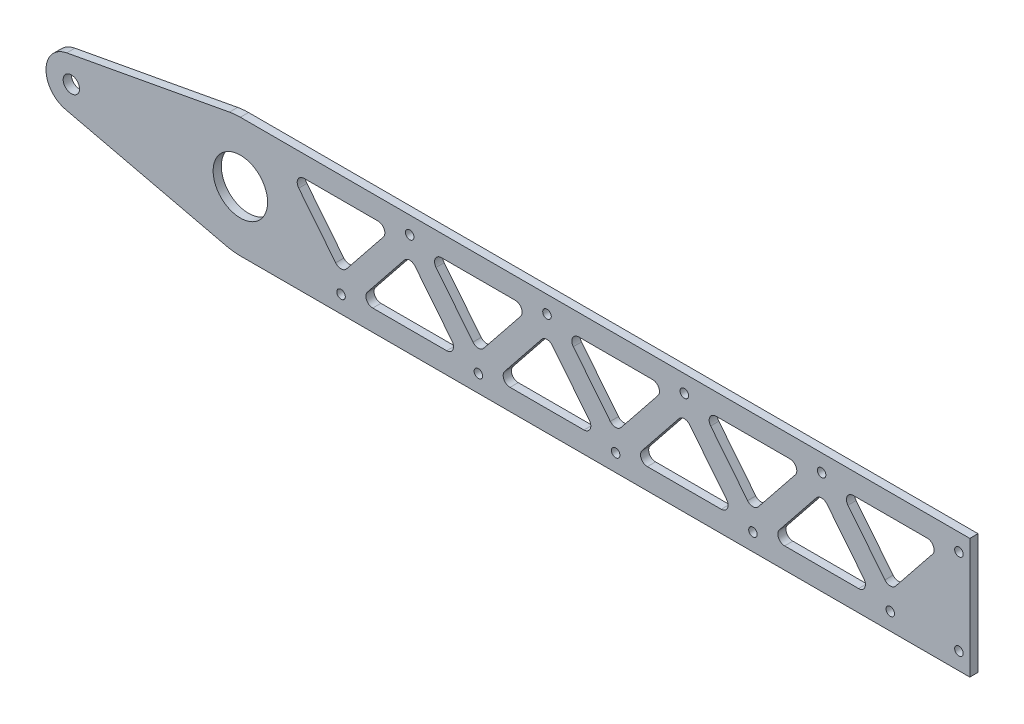
from build123d import *

# Parameters (mm, degrees)
SKETCH1_R                  = 15.875
SKETCH1_R_2                = 4.7625
BOSS_EXTRUDE1_DEPTH        = 4.7625
F_10_CLEARANCE_HOLE1_D     = 4.9784
LPATTERN1_COUNT            = 4
LPATTERN1_PITCH            = 80
CUT_EXTRUDE1_DEPTH         = 10
FILLET1_R                  = 4
CUT_EXTRUDE2_DEPTH         = 5.7625
FILLET2_R                  = 4
LPATTERN2_COUNT            = 4
LPATTERN2_PITCH            = 80
FILLET1_OF_LPATTERN2_R     = 4
LPATTERN3_COUNT            = 3
LPATTERN3_PITCH            = 80
FILLET2_OF_LPATTERN3_R     = 4
LPATTERN4_COUNT            = 2
LPATTERN4_PITCH            = 80
FILLET2_OF_LPATTERN4_R     = 4
LPATTERN5_COUNT            = 2
LPATTERN5_PITCH            = 80
FILLET1_OF_LPATTERN5_R     = 4
F_10_CLEARANCE_HOLE2_D     = 4.9784
F_10_CLEARANCE_HOLE2_DEPTH = 4.7625


with BuildPart() as part:
    # Sketch1 → Boss-Extrude1 (new body)
    with BuildSketch(Plane.XY):
        with BuildLine():
            Line((-212.5, 35), (212.5, 35))
            Line((212.5, 35), (212.5, -35))
            Line((212.5, -35), (-212.5, -35))
            ThreePointArc((-212.5, -35), (-216.530381946, -34.767168728), (-220.507141095, -34.07177265))
            Line((-220.507141095, -34.07177265), (-314.360273, -12.015530461))
            ThreePointArc((-314.360273, -12.015530461), (-325.748634462, 2.719438205), (-313.666145568, 16.890801601))
            Line((-313.666145568, 16.890801601), (-218.862525007, 34.416831283))
            ThreePointArc((-218.862525007, 34.416831283), (-215.694597401, 34.853902901), (-212.5, 35))
        make_face()
        with Locations((-212.5, 0)):
            Circle(SKETCH1_R, mode=Mode.SUBTRACT)
        with Locations((-310.980775301, 2.364817767)):
            Circle(SKETCH1_R_2, mode=Mode.SUBTRACT)
    extrude(amount=BOSS_EXTRUDE1_DEPTH)

    # #10 Clearance Hole1 (through all)
    with Locations(Plane(origin=(0, 0, 0), x_dir=(-1, 0, 0), z_dir=(0, 0, -1))):
        with Locations((-126.15, 25), (-86.15, -25)):
            f_10_clearance_hole1 = Hole(F_10_CLEARANCE_HOLE1_D / 2)

    # LPattern1: #10 Clearance Hole1 ×4
    with Locations(*[(-i * LPATTERN1_PITCH, 0, 0) for i in range(1, LPATTERN1_COUNT)]):
        add(f_10_clearance_hole1, mode=Mode.SUBTRACT)

    # Sketch13 → Cut-Extrude1 (cut)
    with BuildSketch(Plane(origin=(0, 0, 0), x_dir=(-1, 0, 0), z_dir=(0, 0, -1))):
        Polygon((-56.301294523, 22.715958732), (-86.15, -14.594923114), (-115.998705477, 22.715958732), align=None)
    cut_extrude1 = extrude(amount=-CUT_EXTRUDE1_DEPTH, mode=Mode.SUBTRACT)

    # Fillet1
    fillet1_edges = [part.edges().sort_by_distance(p)[0] for p in [
        (56.301294523, 22.715958732, 2.38125),
        (86.15, -14.594923114, 2.38125),
        (115.998705477, 22.715958732, 2.38125),
    ]]
    fillet(fillet1_edges, radius=FILLET1_R)

    # Sketch14 → Cut-Extrude2 (cut, through all)
    with BuildSketch(Plane(origin=(0, 0, 0), x_dir=(-1, 0, 0), z_dir=(0, 0, -1))):
        Polygon((-46.15, 14.594923114), (-75.998705477, -22.715958732), (-16.301294523, -22.715958732), align=None)
    cut_extrude2 = extrude(amount=-CUT_EXTRUDE2_DEPTH, mode=Mode.SUBTRACT)

    # Fillet2
    fillet2_edges = [part.edges().sort_by_distance(p)[0] for p in [
        (46.15, 14.594923114, 2.38125),
        (16.301294523, -22.715958732, 2.38125),
        (75.998705477, -22.715958732, 2.38125),
    ]]
    fillet(fillet2_edges, radius=FILLET2_R)

    # LPattern2: Cut-Extrude1 ×4
    with Locations(*[(-i * LPATTERN2_PITCH, 0, 0) for i in range(1, LPATTERN2_COUNT)]):
        add(cut_extrude1, mode=Mode.SUBTRACT)

    # Fillet1 of LPattern2
    fillet1_of_lpattern2_edges = [part.edges().sort_by_distance(p)[0] for p in [
        (-23.698705477, 22.715958732, 2.38125),
        (6.15, -14.594923114, 2.38125),
        (35.998705477, 22.715958732, 2.38125),
        (-103.698705477, 22.715958732, 2.38125),
        (-73.85, -14.594923114, 2.38125),
        (-44.001294523, 22.715958732, 2.38125),
        (-183.698705477, 22.715958732, 2.38125),
        (-153.85, -14.594923114, 2.38125),
        (-124.001294523, 22.715958732, 2.38125),
    ]]
    fillet(fillet1_of_lpattern2_edges, radius=FILLET1_OF_LPATTERN2_R)

    # LPattern3: Cut-Extrude2 ×3
    with Locations(*[(-i * LPATTERN3_PITCH, 0, 0) for i in range(1, LPATTERN3_COUNT)]):
        add(cut_extrude2, mode=Mode.SUBTRACT)

    # Fillet2 of LPattern3
    fillet2_of_lpattern3_edges = [part.edges().sort_by_distance(p)[0] for p in [
        (-33.85, 14.594923114, 2.38125),
        (-63.698705477, -22.715958732, 2.38125),
        (-4.001294523, -22.715958732, 2.38125),
        (-113.85, 14.594923114, 2.38125),
        (-143.698705477, -22.715958732, 2.38125),
        (-84.001294523, -22.715958732, 2.38125),
    ]]
    fillet(fillet2_of_lpattern3_edges, radius=FILLET2_OF_LPATTERN3_R)

    # LPattern4: Cut-Extrude2 ×2
    with Locations(*[(i * LPATTERN4_PITCH, 0, 0) for i in range(1, LPATTERN4_COUNT)]):
        add(cut_extrude2, mode=Mode.SUBTRACT)

    # Fillet2 of LPattern4
    fillet2_of_lpattern4_edges = [part.edges().sort_by_distance(p)[0] for p in [
        (126.15, 14.594923114, 2.38125),
        (96.301294523, -22.715958732, 2.38125),
        (155.998705477, -22.715958732, 2.38125),
    ]]
    fillet(fillet2_of_lpattern4_edges, radius=FILLET2_OF_LPATTERN4_R)

    # LPattern5: Cut-Extrude1 ×2
    with Locations(*[(i * LPATTERN5_PITCH, 0, 0) for i in range(1, LPATTERN5_COUNT)]):
        add(cut_extrude1, mode=Mode.SUBTRACT)

    # Fillet1 of LPattern5
    fillet1_of_lpattern5_edges = [part.edges().sort_by_distance(p)[0] for p in [
        (136.301294523, 22.715958732, 2.38125),
        (166.15, -14.594923114, 2.38125),
        (195.998705477, 22.715958732, 2.38125),
    ]]
    fillet(fillet1_of_lpattern5_edges, radius=FILLET1_OF_LPATTERN5_R)

    # #10 Clearance Hole2
    with Locations(Plane.XY.offset(4.7625)):
        with Locations((206.15, 25), (206.15, -25), (166.15, -25)):
            Hole(F_10_CLEARANCE_HOLE2_D / 2, depth=F_10_CLEARANCE_HOLE2_DEPTH)


solid = part.part
